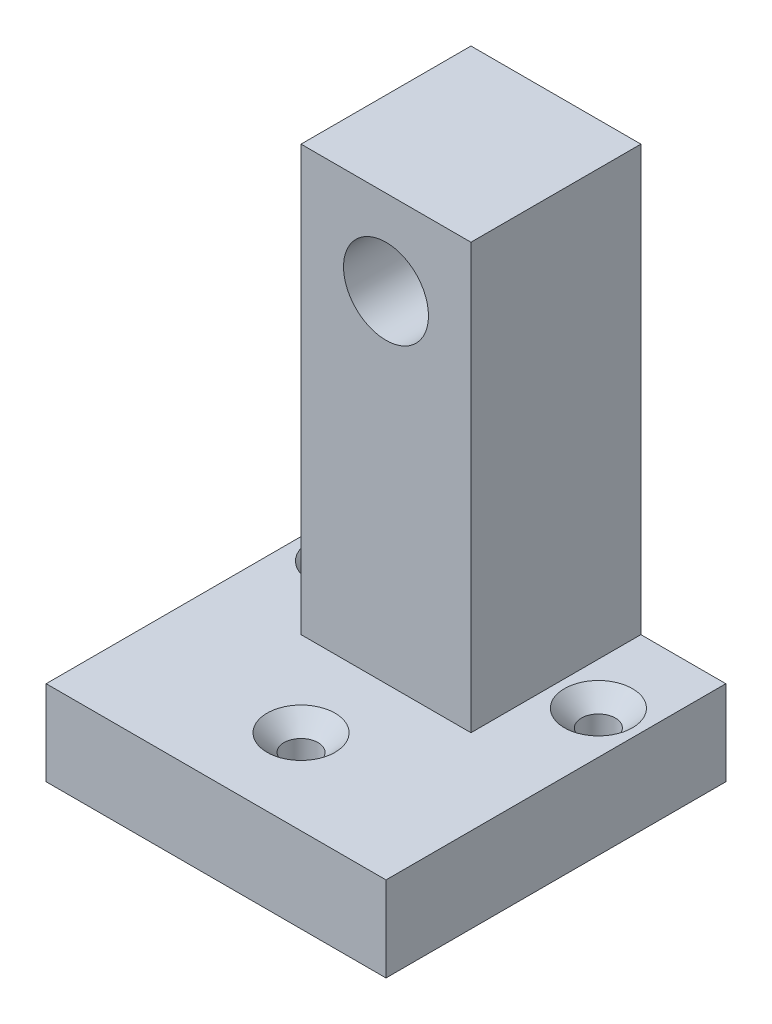
from build123d import *

# Parameters (mm, degrees)
BOSS_EXTRU_2_DEPTH      = 2
BOSS_EXTRU_3_DEPTH      = 2
ESQUISSE4_R             = 0.5
ENL_V_MAT_EXTRU_1_DEPTH = 2
ESQUISSE5_R             = 0.2
ENL_V_MAT_EXTRU_2_DEPTH = 1
ESQUISSE6_R             = 0.2
ENL_V_MAT_EXTRU_3_DEPTH = 1
CHANFREIN1_SIZE         = 0.2
CHANFREIN2_SIZE         = 0.2
CHANFREIN3_SIZE         = 0.2


with BuildPart() as part:
    # Esquisse1 → Boss.-Extru.2 (new body)
    with BuildSketch(Plane.XY):
        Polygon((-4.954240171, 0), (-0.954240171, 0), (-0.954240171, 1), (-1.954240171, 1), (-1.954240171, 6), (-3.954240171, 6), (-3.954240171, 1), (-4.954240171, 1), align=None)
    extrude(amount=BOSS_EXTRU_2_DEPTH)

    # Esquisse3 → Boss.-Extru.3 (add)
    with BuildSketch(Plane.XY.offset(2)):
        Polygon((-3.954240171, 1), (-1.954240171, 1), (-0.954240171, 1), (-0.954240171, 0), (-4.954240171, 0), (-4.954240171, 1), align=None)
    extrude(amount=BOSS_EXTRU_3_DEPTH)

    # Esquisse4 → Enlèv. mat.-Extru.1 (cut)
    with BuildSketch(Plane.XY.offset(2)):
        with Locations((-2.954240171, 5)):
            Circle(ESQUISSE4_R)
    extrude(amount=-ENL_V_MAT_EXTRU_1_DEPTH, mode=Mode.SUBTRACT)

    # Esquisse5 → Enlèv. mat.-Extru.2 (cut)
    with BuildSketch(Plane.ZY.offset(3.954240171)):
        with Locations((1, 5)):
            Circle(ESQUISSE5_R)
    extrude(amount=-ENL_V_MAT_EXTRU_2_DEPTH, mode=Mode.SUBTRACT)

    # Esquisse6 → Enlèv. mat.-Extru.3 (cut)
    with BuildSketch(Plane(origin=(0, 1, 0), x_dir=(1, 0, 0), z_dir=(0, 1, 0))):
        with Locations((-4.454240171, -1)):
            Circle(ESQUISSE6_R)
        with Locations((-1.454240171, -1)):
            Circle(ESQUISSE6_R)
        with Locations((-2.954240171, -3)):
            Circle(ESQUISSE6_R)
    extrude(amount=-ENL_V_MAT_EXTRU_3_DEPTH, mode=Mode.SUBTRACT)

    # Chanfrein1
    chanfrein1_edges = [part.edges().sort_by_distance(p)[0] for p in [
        (-3.154240171, 1, 3),
    ]]
    chamfer(chanfrein1_edges, length=CHANFREIN1_SIZE)

    # Chanfrein2
    chanfrein2_edges = [part.edges().sort_by_distance(p)[0] for p in [
        (-1.654240171, 1, 1),
    ]]
    chamfer(chanfrein2_edges, length=CHANFREIN2_SIZE)

    # Chanfrein3
    chanfrein3_edges = [part.edges().sort_by_distance(p)[0] for p in [
        (-4.654240171, 1, 1),
    ]]
    chamfer(chanfrein3_edges, length=CHANFREIN3_SIZE)


solid = part.part
